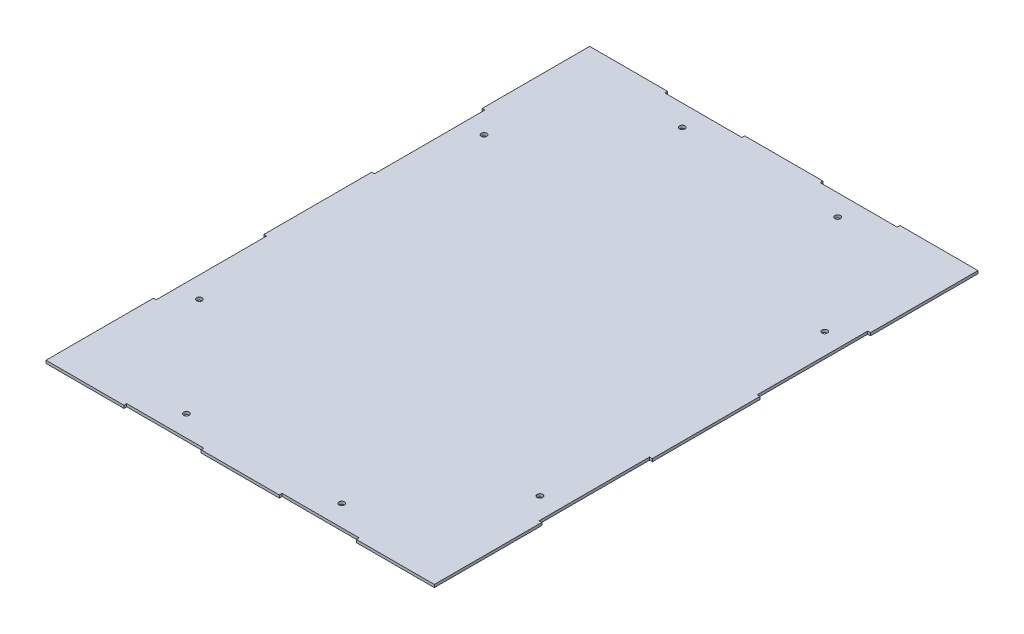
from build123d import *

# Parameters (mm, degrees)
SKETCH1_W           = 350
SKETCH1_H           = 490
BOSS_EXTRUDE1_DEPTH = 2.5
SKETCH2_R           = 2.5
SKETCH2_W           = 69.5
SKETCH2_H           = 2.5
SKETCH2_W_2         = 2.5
SKETCH2_H_2         = 99.5
CUT_EXTRUDE1_DEPTH  = 2.5


with BuildPart() as part:
    # Sketch1 → Boss-Extrude1 (new body)
    with BuildSketch(Plane(origin=(0, 0, 0), x_dir=(1, 0, 0), z_dir=(0, 1, 0))):
        Rectangle(SKETCH1_W, SKETCH1_H)
    extrude(amount=BOSS_EXTRUDE1_DEPTH)

    # Sketch2 → Cut-Extrude1 (cut)
    with BuildSketch(Plane(origin=(0, 2.5, 0), x_dir=(1, 0, 0), z_dir=(0, 1, 0))):
        with Locations((-70, 223.5)):
            Circle(SKETCH2_R)
        with Locations((70, 223.5)):
            Circle(SKETCH2_R)
        with Locations((70, -223.5)):
            Circle(SKETCH2_R)
        with Locations((-70, -223.5)):
            Circle(SKETCH2_R)
        with Locations((-153.5, 128.333333333)):
            Circle(SKETCH2_R)
        with Locations((-153.5, -128.333333333)):
            Circle(SKETCH2_R)
        with Locations((153.5, -128.333333333)):
            Circle(SKETCH2_R)
        with Locations((153.5, 128.333333333)):
            Circle(SKETCH2_R)
        with Locations((-70, 243.75)):
            Rectangle(SKETCH2_W, SKETCH2_H)
        with Locations((-173.75, 98.333333333)):
            Rectangle(SKETCH2_W_2, SKETCH2_H_2)
        with Locations((70, 243.75)):
            Rectangle(SKETCH2_W, SKETCH2_H)
        with Locations((-173.75, -98.333333333)):
            Rectangle(SKETCH2_W_2, SKETCH2_H_2)
        with Locations((173.75, -98.333333333)):
            Rectangle(SKETCH2_W_2, SKETCH2_H_2)
        with Locations((173.75, 98.333333333)):
            Rectangle(SKETCH2_W_2, SKETCH2_H_2)
        with Locations((70, -243.75)):
            Rectangle(SKETCH2_W, SKETCH2_H)
        with Locations((-70, -243.75)):
            Rectangle(SKETCH2_W, SKETCH2_H)
    extrude(amount=-CUT_EXTRUDE1_DEPTH, mode=Mode.SUBTRACT)


solid = part.part
